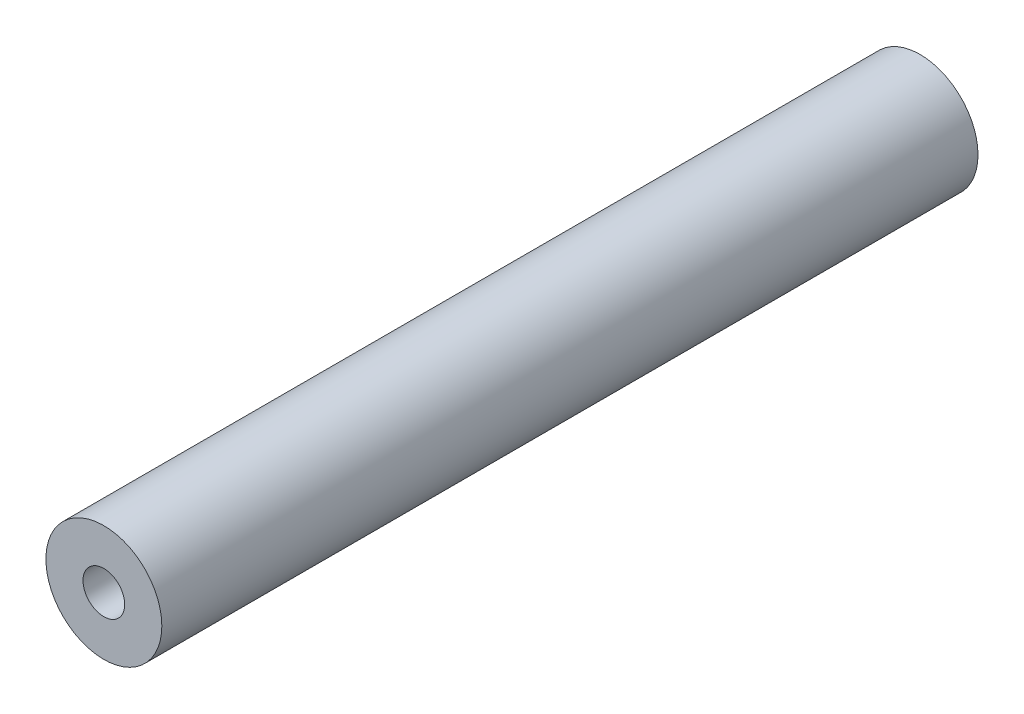
from build123d import *

# Parameters (mm, degrees)
SKETCH1_R           = 31.75
BOSS_EXTRUDE1_DEPTH = 447.04
SKETCH2_R           = 11.43
CUT_EXTRUDE1_DEPTH  = 448.04


with BuildPart() as part:
    # Sketch1 → Boss-Extrude1 (new body)
    with BuildSketch(Plane.XY):
        Circle(SKETCH1_R)
    extrude(amount=BOSS_EXTRUDE1_DEPTH)

    # Sketch2 → Cut-Extrude1 (cut, through all)
    with BuildSketch(Plane.XY.offset(447.04)):
        Circle(SKETCH2_R)
    extrude(amount=-CUT_EXTRUDE1_DEPTH, mode=Mode.SUBTRACT)


solid = part.part
